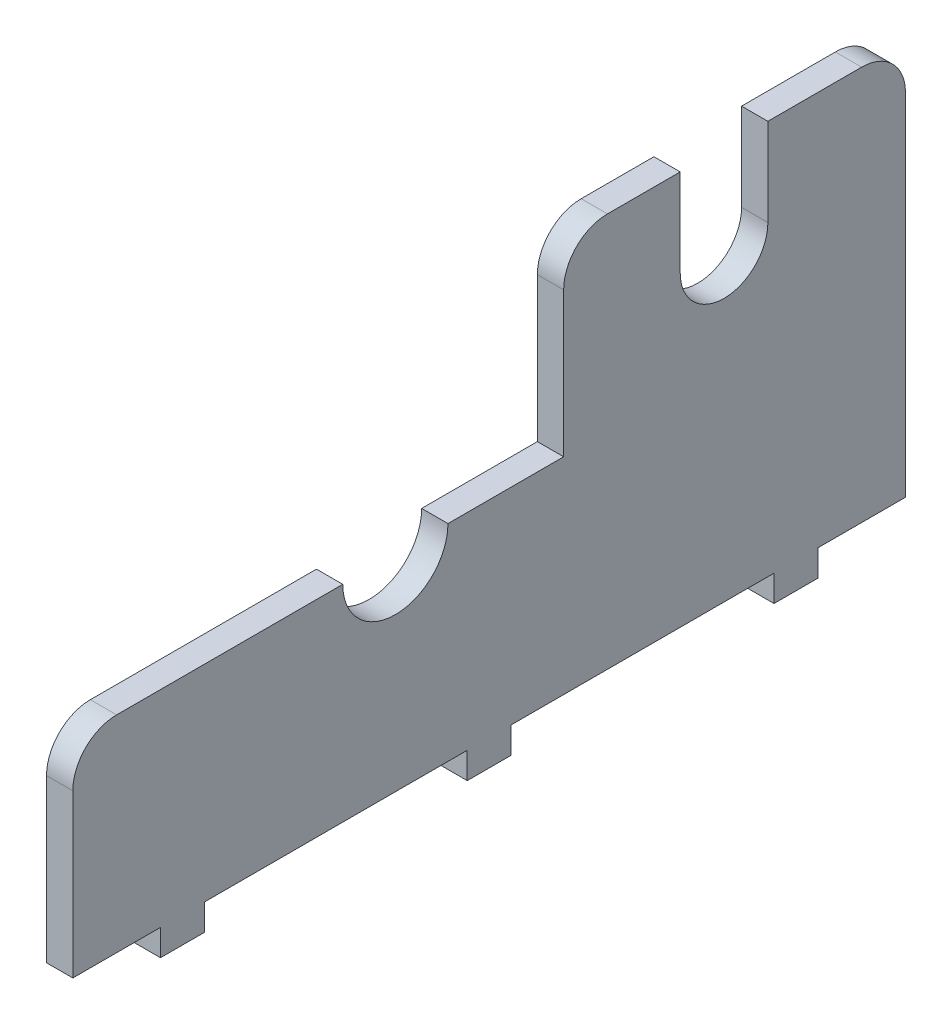
from build123d import *

# Parameters (mm, degrees)
SKETCH1_W           = 95
SKETCH1_H           = 23.5
BOSS_EXTRUDE1_DEPTH = 3
SKETCH2_R           = 6
CUT_EXTRUDE1_DEPTH  = 4
SKETCH4_W           = 3
SKETCH4_H           = 5
BOSS_EXTRUDE2_DEPTH = 3
SKETCH9_W           = 3
SKETCH9_H           = 39
BOSS_EXTRUDE5_DEPTH = 21.5
CUT_EXTRUDE5_DEPTH  = 4
FILLET5_R           = 5
LPATTERN1_COUNT     = 3
LPATTERN1_PITCH     = 35


with BuildPart() as part:
    # Sketch1 → Boss-Extrude1 (new body)
    with BuildSketch(Plane(origin=(0, 0, 0), x_dir=(0, 0, -1), z_dir=(1, 0, 0))):
        with Locations((17.5, 11.75)):
            Rectangle(SKETCH1_W, SKETCH1_H)
    extrude(amount=BOSS_EXTRUDE1_DEPTH)

    # Sketch2 → Cut-Extrude1 (cut, through all)
    with BuildSketch(Plane(origin=(3, 0, 0), x_dir=(0, 0, -1), z_dir=(1, 0, 0))):
        with Locations((6.8, 23.5)):
            Circle(SKETCH2_R)
    extrude(amount=-CUT_EXTRUDE1_DEPTH, mode=Mode.SUBTRACT)

    # Sketch4 → Boss-Extrude2 (add)
    with BuildSketch(Plane.XZ):
        with Locations((1.5, 17.5)):
            Rectangle(SKETCH4_W, SKETCH4_H)
    boss_extrude2 = extrude(amount=BOSS_EXTRUDE2_DEPTH)

    # Sketch9 → Boss-Extrude5 (add)
    with BuildSketch(Plane(origin=(0, 23.5, 0), x_dir=(1, 0, 0), z_dir=(0, 1, 0))):
        with Locations((1.5, 45.5)):
            Rectangle(SKETCH9_W, SKETCH9_H)
    extrude(amount=BOSS_EXTRUDE5_DEPTH)

    # Sketch10 → Cut-Extrude5 (cut, through all)
    with BuildSketch(Plane(origin=(3, 0, 0), x_dir=(0, 0, -1), z_dir=(1, 0, 0))):
        with BuildLine():
            Line((39.3, 35), (39.3, 45))
            Line((39.3, 45), (49.3, 45))
            Line((49.3, 45), (49.3, 35))
            ThreePointArc((49.3, 35), (44.3, 30), (39.3, 35))
        make_face()
    extrude(amount=-CUT_EXTRUDE5_DEPTH, mode=Mode.SUBTRACT)

    # Fillet5
    fillet5_edges = [part.edges().sort_by_distance(p)[0] for p in [
        (1.5, 45, -26),
        (1.5, 45, -65),
        (1.5, 23.5, 30),
    ]]
    fillet(fillet5_edges, radius=FILLET5_R)

    # LPattern1: Boss-Extrude2 ×3
    with Locations(*[(0, 0, -i * LPATTERN1_PITCH) for i in range(1, LPATTERN1_COUNT)]):
        add(boss_extrude2)


solid = part.part
